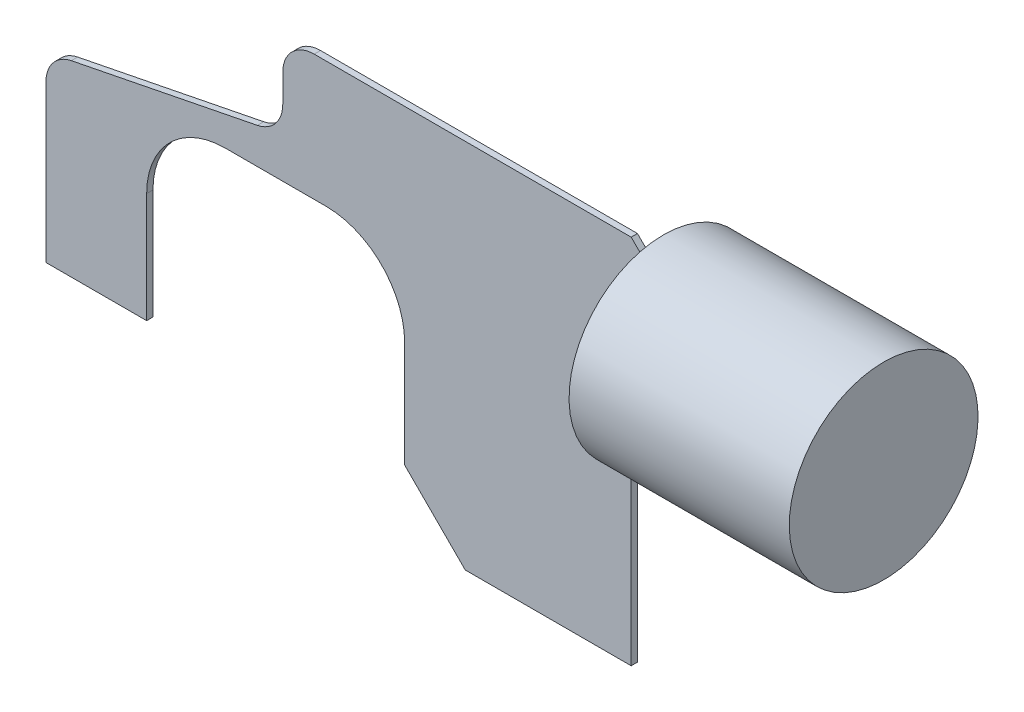
from build123d import *

# Parameters (mm, degrees)
BOSS_EXTRUDE1_DEPTH = 0.127
SKETCH5_R           = 3.81
BOSS_EXTRUDE2_DEPTH = 8.89
CUT_EXTRUDE1_DEPTH  = 4.937
CUT_EXTRUDE3_DEPTH  = 2.54


with BuildPart() as part:
    # Sketch1 → Boss-Extrude1 (new body, symmetric)
    with BuildSketch(Plane.XY):
        with BuildLine():
            Line((0, 0), (0, 9.525))
            ThreePointArc((0, 9.525), (0.92993597, 11.77006403), (3.175, 12.7))
            Line((3.175, 12.7), (23.622, 12.7))
            Line((23.622, 12.7), (24.79704807, 11.52495193))
            Line((24.79704807, 11.52495193), (24.79704807, 7.52504807))
            Line((24.79704807, 7.52504807), (23.622, 6.35))
            Line((23.622, 6.35), (23.622, -2.286))
            Line((23.622, -2.286), (16.92369646, -2.286))
            Line((16.92369646, -2.286), (14.478, 0.15969646))
            Line((14.478, 0.15969646), (14.478, 4.445))
            ThreePointArc((14.478, 4.445), (13.54806403, 6.69006403), (11.303, 7.62))
            Line((11.303, 7.62), (7.239, 7.62))
            ThreePointArc((7.239, 7.62), (4.99393597, 6.69006403), (4.064, 4.445))
            Line((4.064, 4.445), (4.064, 0))
            Line((4.064, 0), (0, 0))
        make_face()
    extrude(amount=BOSS_EXTRUDE1_DEPTH, both=True)

    # Sketch5 → Boss-Extrude2 (add)
    with BuildSketch(Plane(origin=(24.79704807, 0, 0), x_dir=(0, 0, -1), z_dir=(1, 0, 0))):
        with Locations((0, 9.49295193)):
            Circle(SKETCH5_R)
    extrude(amount=BOSS_EXTRUDE2_DEPTH)

    # Sketch6 → Cut-Extrude1 (cut, through all)
    with BuildSketch(Plane.XY.offset(0.127)):
        Polygon((4.826, 10.922), (4.826, 8.382), (9.144, 9.652), align=None)
    extrude(amount=-CUT_EXTRUDE1_DEPTH, mode=Mode.SUBTRACT)

    # Sketch8 → Cut-Extrude3 (cut)
    with BuildSketch(Plane(origin=(0, 0, -0.127), x_dir=(-1, 0, 0), z_dir=(0, 0, -1))):
        with BuildLine():
            ThreePointArc((-10.82704807, 12.7), (-9.929022457, 12.328025612), (-9.55704807, 11.43))
            Line((-9.55704807, 11.43), (-9.55704807, 10.308777788))
            ThreePointArc((-9.55704807, 10.308777788), (-9.268748673, 9.503070692), (-8.534742676, 9.06316654))
            Line((-8.534742676, 9.06316654), (-1.022305393, 7.569289375))
            ThreePointArc((-1.022305393, 7.569289375), (-0.288299396, 7.129385223), (0, 6.323678127))
            Line((0, 6.323678127), (0, 9.525))
            ThreePointArc((0, 9.525), (-0.92993597, 11.77006403), (-3.175, 12.7))
            Line((-3.175, 12.7), (-10.82704807, 12.7))
        make_face()
        Polygon((-4.826, 8.382), (-9.144, 9.652), (-4.826, 10.922), align=None, mode=Mode.SUBTRACT)
    extrude(amount=-CUT_EXTRUDE3_DEPTH, mode=Mode.SUBTRACT)


solid = part.part
